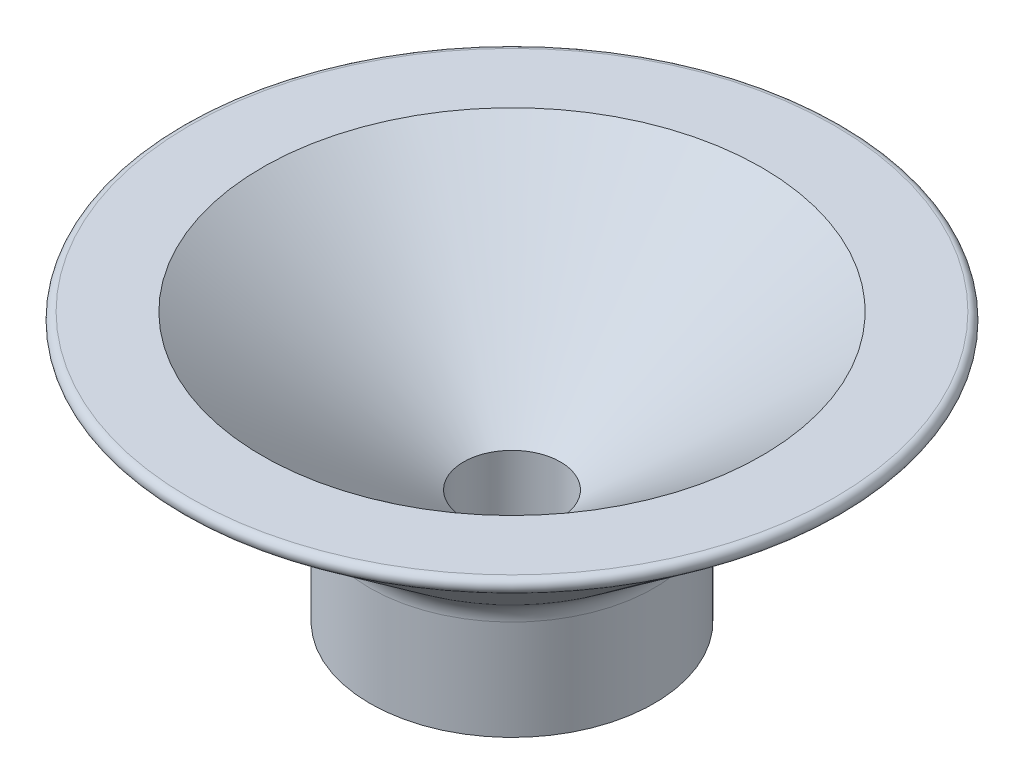
from build123d import *

# Parameters (mm, degrees)
SKETCH2_R           = 4.986862764
SKETCH2_R_2         = 1.7
BOSS_EXTRUDE1_DEPTH = 4
FILLET1_R           = 0.25
FILLET2_R           = 1


with BuildPart() as part:
    # Sketch1 → Revolve1 (revolve)
    with BuildSketch(Plane.XY):
        Polygon((-1.7, 0), (-4.986862764, 0), (-12.050794784, 5.416408), (-8.76393202, 5.416408), align=None)
    revolve(axis=Axis((0, 0, 0), (0, 1, 0)))

    # Sketch2 → Boss-Extrude1 (add)
    with BuildSketch(Plane.XZ):
        Circle(SKETCH2_R)
        Circle(SKETCH2_R_2, mode=Mode.SUBTRACT)
    extrude(amount=BOSS_EXTRUDE1_DEPTH)

    # Fillet1
    fillet1_edges = [part.edges().sort_by_distance(p)[0] for p in [
        (12.050794784, 5.416408, 0),
    ]]
    fillet(fillet1_edges, radius=FILLET1_R)

    # Fillet2
    fillet2_edges = [part.edges().sort_by_distance(p)[0] for p in [
        (0, 0, -4.986862764),
    ]]
    fillet(fillet2_edges, radius=FILLET2_R)


solid = part.part
